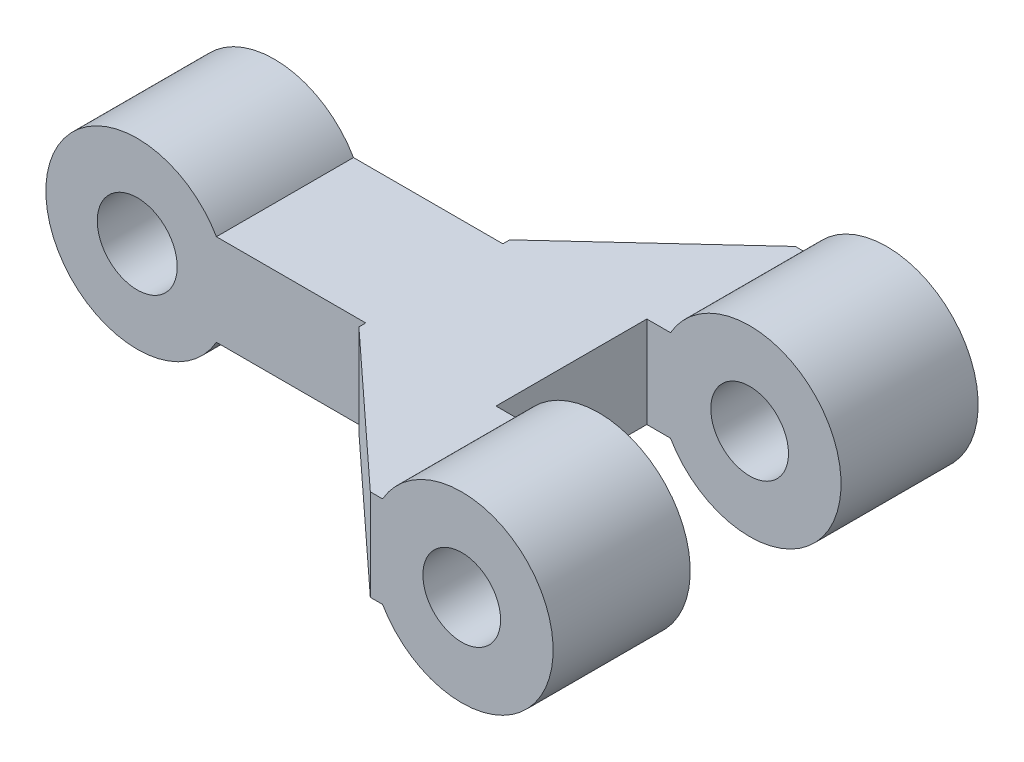
from build123d import *

# Parameters (mm, degrees)
SKETCH_1_R           = 4
SKETCH_1_R_2         = 1.7
EXTRUDE_1_DEPTH      = 6
EXTRUDE_2_DEPTH      = 2
EXTRUDE_2_DEPTH_BACK = 2
EXTRUDE_3_DEPTH      = 3
EXTRUDE_3_DEPTH_BACK = 3
SKETCH_3_R           = 1.75


with BuildPart() as part:
    # Эскиз1 → Бобышка-Вытянуть1 (new body)
    with BuildSketch(Plane.XY):
        Circle(SKETCH_1_R)
        Circle(SKETCH_1_R_2, mode=Mode.SUBTRACT)
    extrude_1 = extrude(amount=EXTRUDE_1_DEPTH)

    # Эскиз2 → Бобышка-Вытянуть2 (add, two sides: drawn at the far end of the back side and taken through both)
    with BuildSketch(Plane(origin=(0, 0, 0), x_dir=(1, 0, 0), z_dir=(0, 1, 0)).offset(-EXTRUDE_2_DEPTH_BACK)):
        Polygon((-4, 0), (-10.5, -6), (-10.5, -12.6), (-4, -18.6), (-3, -18.6), (-3, -12.6), (-4, -12.6), (-4.5, -12.6), (-4.5, -6), (-4, -6), (-3, -6), (-3, 0), align=None)
    extrude(amount=EXTRUDE_2_DEPTH + EXTRUDE_2_DEPTH_BACK)

    # Зеркальное отражение1: Бобышка-Вытянуть1 across plane
    add(extrude_1.mirror(Plane(origin=(0, 0, 9.3), x_dir=(1, 0, 0), z_dir=(0, 0, -1))))

    # Эскиз3 → Бобышка-Вытянуть3 (add, two sides: drawn at the far end of the back side and taken through both)
    with BuildSketch(Plane(origin=(0, 0, 9.3), x_dir=(-1, 0, 0), z_dir=(0, 0, -1)).offset(-EXTRUDE_3_DEPTH_BACK)):
        with BuildLine():
            Line((10.5, 2), (17.035898385, 2))
            ThreePointArc((17.035898385, 2), (24.5, 0), (17.035898385, -2))
            Line((17.035898385, -2), (10.5, -2))
            Line((10.5, -2), (10.5, 2))
        make_face()
        with Locations((20.5, 0)):
            Circle(SKETCH_3_R, mode=Mode.SUBTRACT)
    extrude(amount=EXTRUDE_3_DEPTH + EXTRUDE_3_DEPTH_BACK)


solid = part.part
